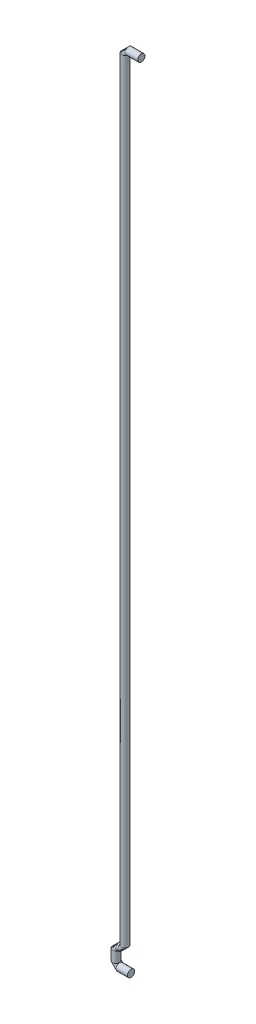
from build123d import *

# Parameters (mm, degrees)
SKETCH3_R = 1


with BuildPart() as part:
    # Sweep3: sweep along a path in Sketch1
    with BuildLine(Plane.XY) as sweep3_path:
        Line((4.5, 221.1), (1, 221.1))
        ThreePointArc((1, 221.1), (0.292893219, 220.807106781), (0, 220.1))
        Line((0, 220.1), (0, 6))
        ThreePointArc((0, 6), (-0.292893219, 5.292893219), (-1, 5))
        Line((-1, 5), (-1.5, 5))
        ThreePointArc((-1.5, 5), (-2.207106781, 4.707106781), (-2.5, 4))
        Line((-2.5, 4), (-2.5, 1))
        ThreePointArc((-2.5, 1), (-2.207106781, 0.292893219), (-1.5, 0))
        Line((-1.5, 0), (1.65, 0))
    # Sketch3 → Sweep3 (sweep)
    with BuildSketch(Plane(origin=(1.65, 0, 0), x_dir=(0, 0, -1), z_dir=(1, 0, 0))):
        Circle(SKETCH3_R)
    sweep(path=sweep3_path.line)


solid = part.part
